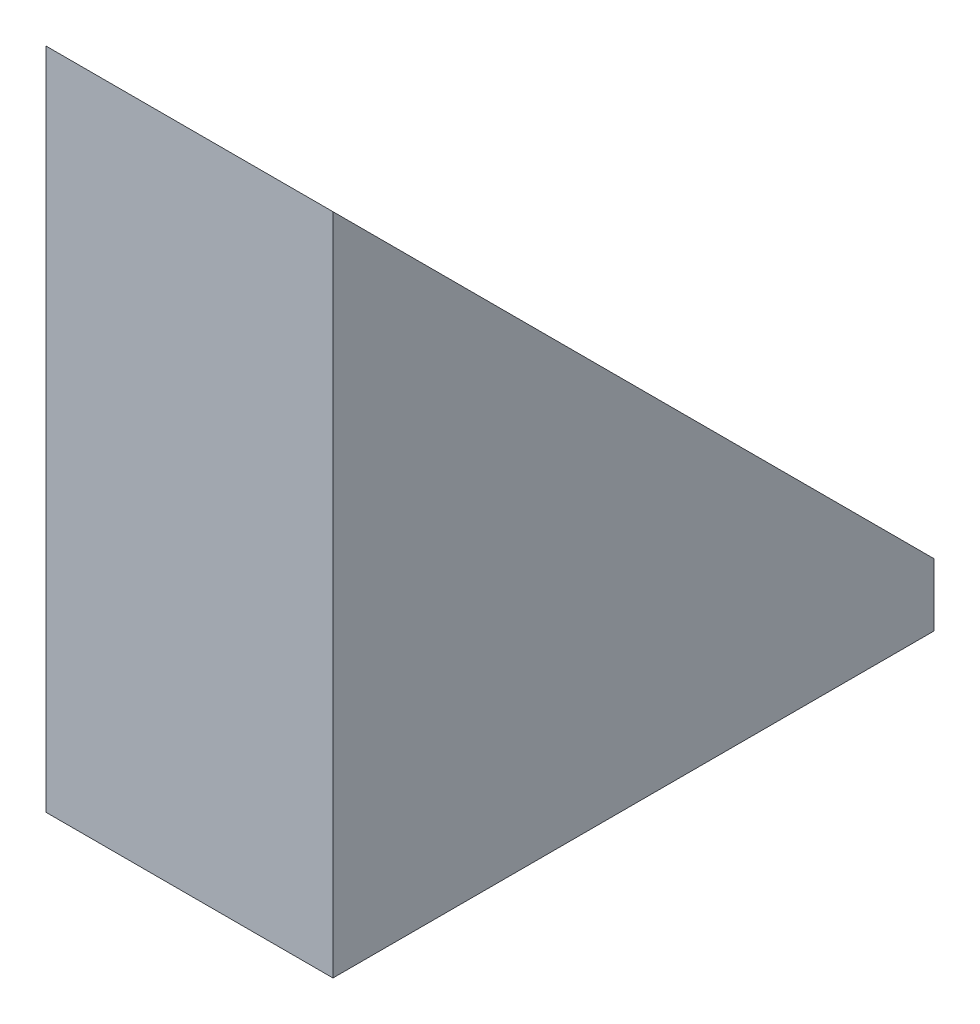
from build123d import *

# Parameters (mm, degrees)
SKETCH1_W           = 167.55342283
SKETCH1_H           = 17.466611717
BOSS_EXTRUDE1_DEPTH = 80


with BuildPart() as part:
    # Sketch1 → Boss-Extrude1 (new body)
    with BuildSketch(Plane.ZY.offset(23229.740351481)):
        Polygon((40276.653618886, 5478.139827453), (40276.653618886, 5310.586404623), (40109.100196056, 5310.586404623), align=None)
        with Locations((40192.876907471, 5301.853098764)):
            Rectangle(SKETCH1_W, SKETCH1_H)
    extrude(amount=-BOSS_EXTRUDE1_DEPTH)


solid = part.part
